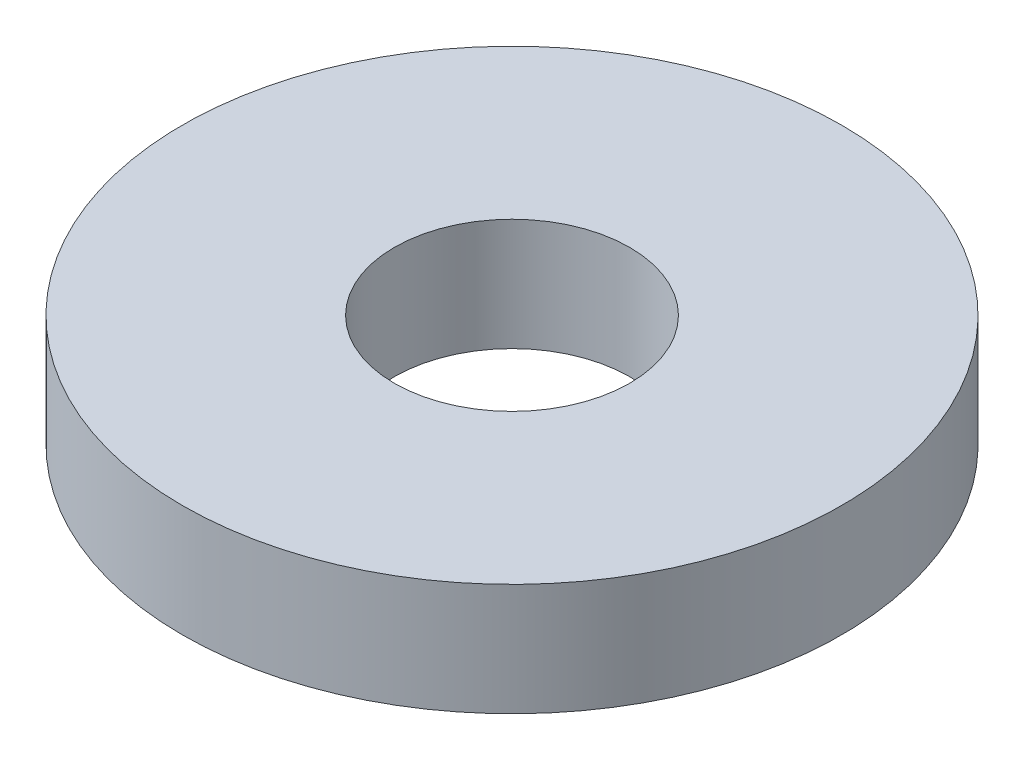
from build123d import *

# Parameters (mm, degrees)
SKETCH1_R           = 35
SKETCH1_R_2         = 12.5
BOSS_EXTRUDE1_DEPTH = 11.9


with BuildPart() as part:
    # Sketch1 → Boss-Extrude1 (new body)
    with BuildSketch(Plane(origin=(0, 0, 0), x_dir=(1, 0, 0), z_dir=(0, 1, 0))):
        Circle(SKETCH1_R)
        Circle(SKETCH1_R_2, mode=Mode.SUBTRACT)
    extrude(amount=BOSS_EXTRUDE1_DEPTH)


solid = part.part
